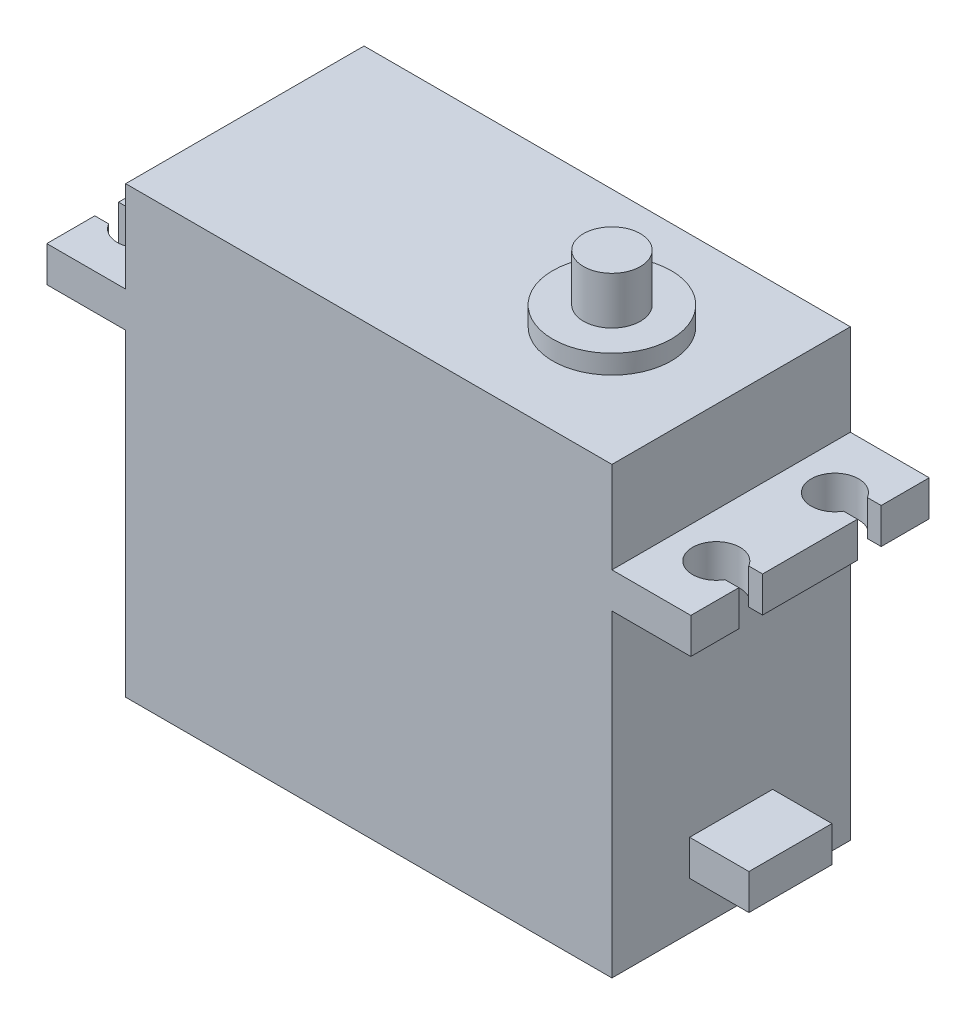
from build123d import *

# Parameters (mm, degrees)
BOSS_EXTRUDE1_START = -10.05
BOSS_EXTRUDE1_DEPTH = 20.1
CUT_EXTRUDE1_DEPTH  = 30.8
SKETCH5_R           = 5
BOSS_EXTRUDE2_DEPTH = 1.6
SKETCH6_R           = 2.4
BOSS_EXTRUDE3_DEPTH = 4
SKETCH8_W           = 7
SKETCH8_H           = 3
BOSS_EXTRUDE4_DEPTH = 5


with BuildPart() as part:
    # Sketch3 → Boss-Extrude1 (new body)
    with BuildSketch(Plane.XY.offset(BOSS_EXTRUDE1_START)):
        Polygon((-30.95, 0), (-30.95, 26.8), (-37.6, 26.8), (-37.6, 29.8), (-30.95, 29.8), (-30.95, 37.5), (10.05, 37.5), (10.05, 29.8), (16.7, 29.8), (16.7, 26.8), (10.05, 26.8), (10.05, 0), align=None)
    extrude(amount=BOSS_EXTRUDE1_DEPTH)

    # Sketch4 → Cut-Extrude1 (cut, through all)
    with BuildSketch(Plane(origin=(0, 29.8, 0), x_dir=(1, 0, 0), z_dir=(0, 1, 0))):
        with BuildLine():
            Line((-37.6, 6), (-37.6, 4))
            Line((-37.6, 4), (-36.432050808, 4))
            ThreePointArc((-36.432050808, 4), (-32.7, 5), (-36.432050808, 6))
            Line((-36.432050808, 6), (-37.6, 6))
        make_face()
        with BuildLine():
            Line((16.7, -6), (15.532050808, -6))
            ThreePointArc((15.532050808, -6), (11.8, -5), (15.532050808, -4))
            Line((15.532050808, -4), (16.7, -4))
            Line((16.7, -4), (16.7, -6))
        make_face()
        with BuildLine():
            Line((-37.6, -4), (-37.6, -6))
            Line((-37.6, -6), (-36.432050808, -6))
            ThreePointArc((-36.432050808, -6), (-32.7, -5), (-36.432050808, -4))
            Line((-36.432050808, -4), (-37.6, -4))
        make_face()
        with BuildLine():
            Line((16.7, 4), (15.532050808, 4))
            ThreePointArc((15.532050808, 4), (11.8, 5), (15.532050808, 6))
            Line((15.532050808, 6), (16.7, 6))
            Line((16.7, 6), (16.7, 4))
        make_face()
    extrude(amount=-CUT_EXTRUDE1_DEPTH, mode=Mode.SUBTRACT)

    # Sketch5 → Boss-Extrude2 (add)
    with BuildSketch(Plane(origin=(0, 37.5, 0), x_dir=(1, 0, 0), z_dir=(0, 1, 0))):
        Circle(SKETCH5_R)
    extrude(amount=BOSS_EXTRUDE2_DEPTH)

    # Sketch6 → Boss-Extrude3 (add)
    with BuildSketch(Plane(origin=(0, 39.1, 0), x_dir=(1, 0, 0), z_dir=(0, 1, 0))):
        Circle(SKETCH6_R)
    extrude(amount=BOSS_EXTRUDE3_DEPTH)

    # Sketch8 → Boss-Extrude4 (add)
    with BuildSketch(Plane(origin=(10.05, 0, 0), x_dir=(0, 0, -1), z_dir=(1, 0, 0))):
        with Locations((0, 5.5)):
            Rectangle(SKETCH8_W, SKETCH8_H)
    extrude(amount=BOSS_EXTRUDE4_DEPTH)


solid = part.part
